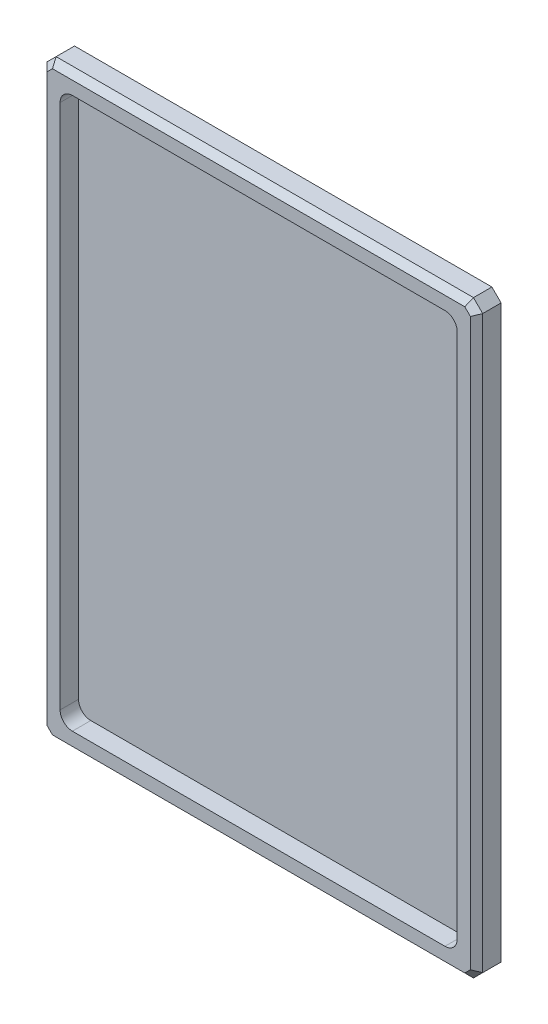
from build123d import *

# Parameters (mm, degrees)
SKETCH1_W           = 225.425
SKETCH1_H           = 304.8
BOSS_EXTRUDE1_DEPTH = 12.7
CUT_EXTRUDE1_DEPTH  = 9.525
CHAMFER2_SIZE       = 4.7625
CHAMFER1_SIZE       = 3.175


with BuildPart() as part:
    # Sketch1 → Boss-Extrude1 (new body)
    with BuildSketch(Plane.XY):
        Rectangle(SKETCH1_W, SKETCH1_H)
    extrude(amount=BOSS_EXTRUDE1_DEPTH)

    # Sketch2 → Cut-Extrude1 (cut)
    with BuildSketch(Plane.XY.offset(12.7)):
        with BuildLine():
            Line((96.3625, -142.4), (-96.3625, -142.4))
            ThreePointArc((-96.3625, -142.4), (-100.852628061, -140.540128061), (-102.7125, -136.05))
            Line((-102.7125, -136.05), (-102.7125, 136.05))
            ThreePointArc((-102.7125, 136.05), (-100.852628061, 140.540128061), (-96.3625, 142.4))
            Line((-96.3625, 142.4), (96.3625, 142.4))
            ThreePointArc((96.3625, 142.4), (100.852628061, 140.540128061), (102.7125, 136.05))
            Line((102.7125, 136.05), (102.7125, -136.05))
            ThreePointArc((102.7125, -136.05), (100.852628061, -140.540128061), (96.3625, -142.4))
        make_face()
    extrude(amount=-CUT_EXTRUDE1_DEPTH, mode=Mode.SUBTRACT)

    # Chamfer2
    chamfer2_edges = [part.edges().sort_by_distance(p)[0] for p in [
        (-112.7125, 152.4, 6.35),
        (112.7125, 152.4, 6.35),
        (112.7125, -152.4, 6.35),
        (-112.7125, -152.4, 6.35),
    ]]
    chamfer(chamfer2_edges, length=CHAMFER2_SIZE)

    # Chamfer1
    chamfer1_edges = [part.edges().sort_by_distance(p)[0] for p in [
        (0, -152.4, 12.7),
        (-112.7125, 0, 12.7),
        (112.7125, 0, 12.7),
        (0, 152.4, 12.7),
        (110.33125, 150.01875, 12.7),
        (110.33125, -150.01875, 12.7),
        (-110.33125, 150.01875, 12.7),
        (-110.33125, -150.01875, 12.7),
    ]]
    chamfer(chamfer1_edges, length=CHAMFER1_SIZE)


solid = part.part
